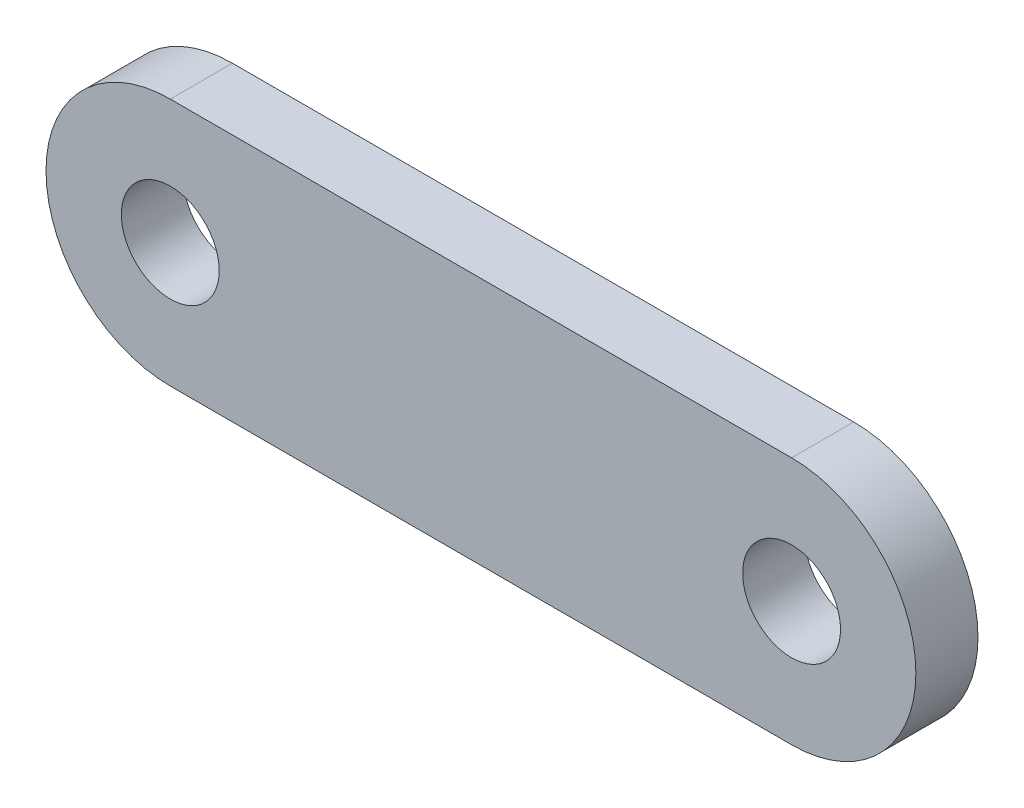
from build123d import *

# Parameters (mm, degrees)
SKETCH1_R           = 1.575
BOSS_EXTRUDE1_DEPTH = 2


with BuildPart() as part:
    # Sketch1 → Boss-Extrude1 (new body)
    with BuildSketch(Plane.XY):
        with BuildLine():
            Line((0, 4), (20, 4))
            ThreePointArc((20, 4), (24, 0), (20, -4))
            Line((20, -4), (0, -4))
            ThreePointArc((0, -4), (-4, 0), (0, 4))
        make_face()
        Circle(SKETCH1_R, mode=Mode.SUBTRACT)
        with Locations((20, 0)):
            Circle(SKETCH1_R, mode=Mode.SUBTRACT)
    extrude(amount=BOSS_EXTRUDE1_DEPTH)


solid = part.part
